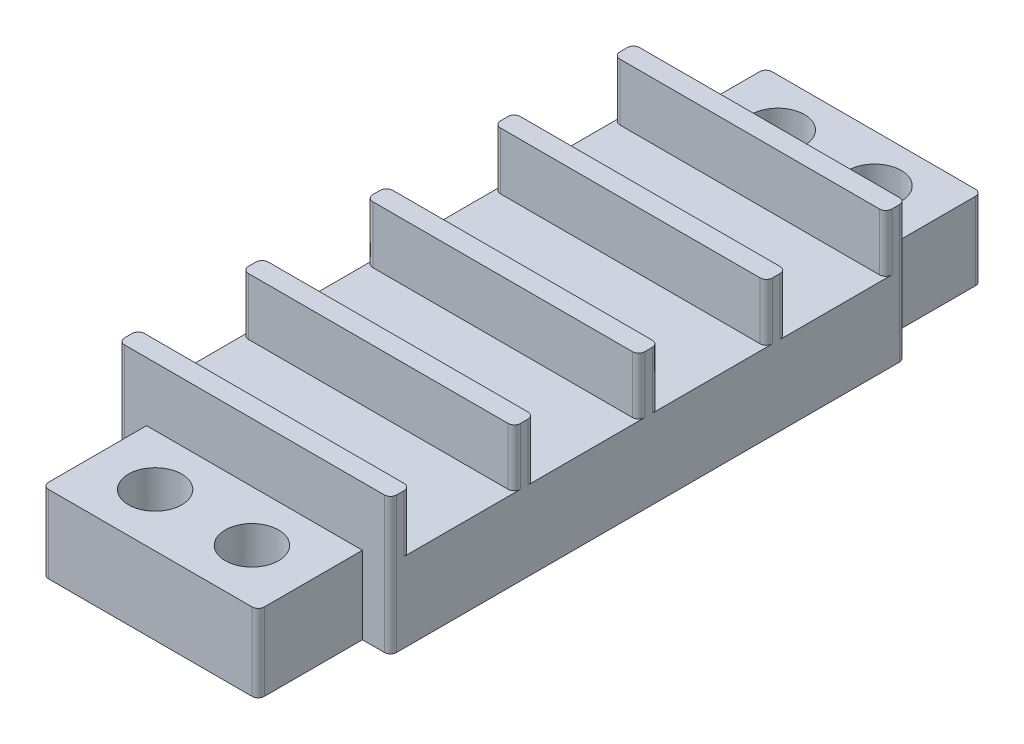
from build123d import *

# Parameters (mm, degrees)
SKETCH1_W           = 21.93
SKETCH1_H           = 41.52
BOSS_EXTRUDE2_DEPTH = 11
SKETCH3_W           = 21.93
SKETCH3_H           = 8.38
SKETCH3_H_2         = 8.42274565
SKETCH3_H_3         = 8.694734819
SKETCH3_W_2         = 22
SKETCH3_H_4         = 8.022519531
CUT_EXTRUDE2_DEPTH  = 4.6
BOSS_EXTRUDE3_START = 20.76
SKETCH5_W           = 17.4
SKETCH5_H           = 6.25
BOSS_EXTRUDE3_DEPTH = 8.4
SKETCH6_R           = 2.15
CUT_EXTRUDE3_DEPTH  = 8.4
SKETCH7_W           = 17.4
SKETCH7_H           = 6.25
BOSS_EXTRUDE4_DEPTH = 8.4
SKETCH9_R           = 2.15
CUT_EXTRUDE4_DEPTH  = 6.25
FILLET2_R           = 0.5


with BuildPart() as part:
    # Sketch1 → Boss-Extrude2 (new body)
    with BuildSketch(Plane(origin=(0, 0, 0), x_dir=(1, 0, 0), z_dir=(0, 1, 0))):
        Rectangle(SKETCH1_W, SKETCH1_H)
    extrude(amount=BOSS_EXTRUDE2_DEPTH)

    # Sketch3 → Cut-Extrude2 (cut)
    with BuildSketch(Plane(origin=(0, 11, 0), x_dir=(1, 0, 0), z_dir=(0, 1, 0))):
        with Locations((0, -14.97)):
            Rectangle(SKETCH3_W, SKETCH3_H)
        with Locations((0, -4.968627175)):
            Rectangle(SKETCH3_W, SKETCH3_H_2)
        with Locations((0, 5.190113059)):
            Rectangle(SKETCH3_W, SKETCH3_H_3)
        with Locations((0.013958332, 15.148740234)):
            Rectangle(SKETCH3_W_2, SKETCH3_H_4)
    extrude(amount=-CUT_EXTRUDE2_DEPTH, mode=Mode.SUBTRACT)

    # Sketch5 → Boss-Extrude3 (add)
    with BuildSketch(Plane.XY.offset(BOSS_EXTRUDE3_START)):
        with Locations((0, 3.125184184)):
            Rectangle(SKETCH5_W, SKETCH5_H)
    extrude(amount=BOSS_EXTRUDE3_DEPTH)

    # Sketch6 → Cut-Extrude3 (cut)
    with BuildSketch(Plane(origin=(0, 6.250184184, 0), x_dir=(1, 0, 0), z_dir=(0, 1, 0))):
        with Locations((-3.9, -24.867133618)):
            Circle(SKETCH6_R)
        with Locations((3.9, -24.867133618)):
            Circle(SKETCH6_R)
    extrude(amount=-CUT_EXTRUDE3_DEPTH, mode=Mode.SUBTRACT)

    # Sketch7 → Boss-Extrude4 (add)
    with BuildSketch(Plane(origin=(0, 0, -20.76), x_dir=(-1, 0, 0), z_dir=(0, 0, -1))):
        with Locations((0, 3.128849309)):
            Rectangle(SKETCH7_W, SKETCH7_H)
    extrude(amount=BOSS_EXTRUDE4_DEPTH)

    # Sketch9 → Cut-Extrude4 (cut)
    with BuildSketch(Plane(origin=(0, 6.253849309, 0), x_dir=(1, 0, 0), z_dir=(0, 1, 0))):
        with Locations((-3.9, 25.32626204)):
            Circle(SKETCH9_R)
        with Locations((3.9, 25.32626204)):
            Circle(SKETCH9_R)
    extrude(amount=-CUT_EXTRUDE4_DEPTH, mode=Mode.SUBTRACT)

    # Fillet2
    fillet2_edges = [part.edges().sort_by_distance(p)[0] for p in [
        (8.7, 3.128849309, -29.16),
        (-8.7, 3.128849309, -29.16),
        (-10.965, 8.7, 19.16),
        (-10.965, 8.7, 10.78),
        (10.965, 8.7, 10.78),
        (10.965, 8.7, 19.16),
        (-10.965, 8.7, 9.18),
        (-10.965, 8.7, 0.75725435),
        (10.965, 8.7, 0.75725435),
        (10.965, 8.7, 9.18),
        (-10.965, 8.7, -0.84274565),
        (-10.965, 8.7, -9.537480469),
        (10.965, 8.7, -9.537480469),
        (10.965, 8.7, -0.84274565),
        (10.965, 8.7, -19.16),
        (-10.965, 8.7, -19.16),
        (10.965, 8.7, -11.137480469),
        (-10.965, 8.7, -11.137480469),
        (10.965, 5.5, 20.76),
        (10.965, 5.5, -20.76),
        (-10.965, 5.5, -20.76),
        (-10.965, 5.5, 20.76),
        (-8.7, 3.125184184, 29.16),
        (8.7, 3.125184184, 29.16),
    ]]
    fillet(fillet2_edges, radius=FILLET2_R)


solid = part.part
